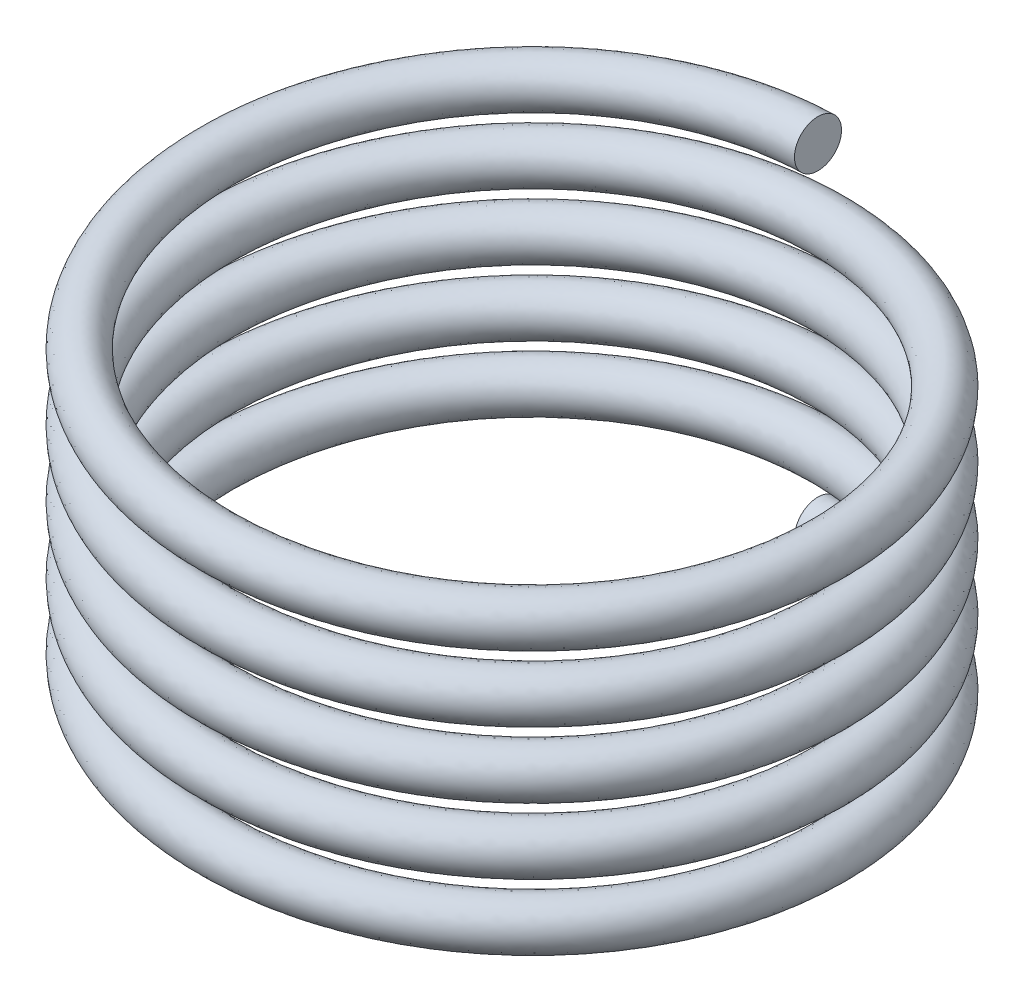
from build123d import *

# Parameters (mm, degrees)
PEREGRINE_SPRING_PITCH       = 1.778
PEREGRINE_SPRING_HEIGHT      = 8.89
PEREGRINE_SPRING_RADIUS      = 8.255
PEREGRINE_SPRING_START_ANGLE = -180
SKETCH2_R                    = 0.635


with BuildPart() as part:
    # Peregrine Spring: sweep along a helix
    with BuildLine() as peregrine_spring_path:
        add(Helix(PEREGRINE_SPRING_PITCH, PEREGRINE_SPRING_HEIGHT, PEREGRINE_SPRING_RADIUS, center=(0, 0, 0), direction=(0, 1, 0), lefthand=True, mode=Mode.PRIVATE).rotate(Axis((0, 0, 0), (0, 1, 0)), PEREGRINE_SPRING_START_ANGLE))
    # Sketch2 → Peregrine Spring (sweep)
    with BuildSketch(Plane(origin=(0, 0, 0), x_dir=(0, 0, -1), z_dir=(1, 0, 0))):
        with Locations((8.255, 0)):
            Circle(SKETCH2_R)
    sweep(path=peregrine_spring_path.line, is_frenet=True)


solid = part.part
